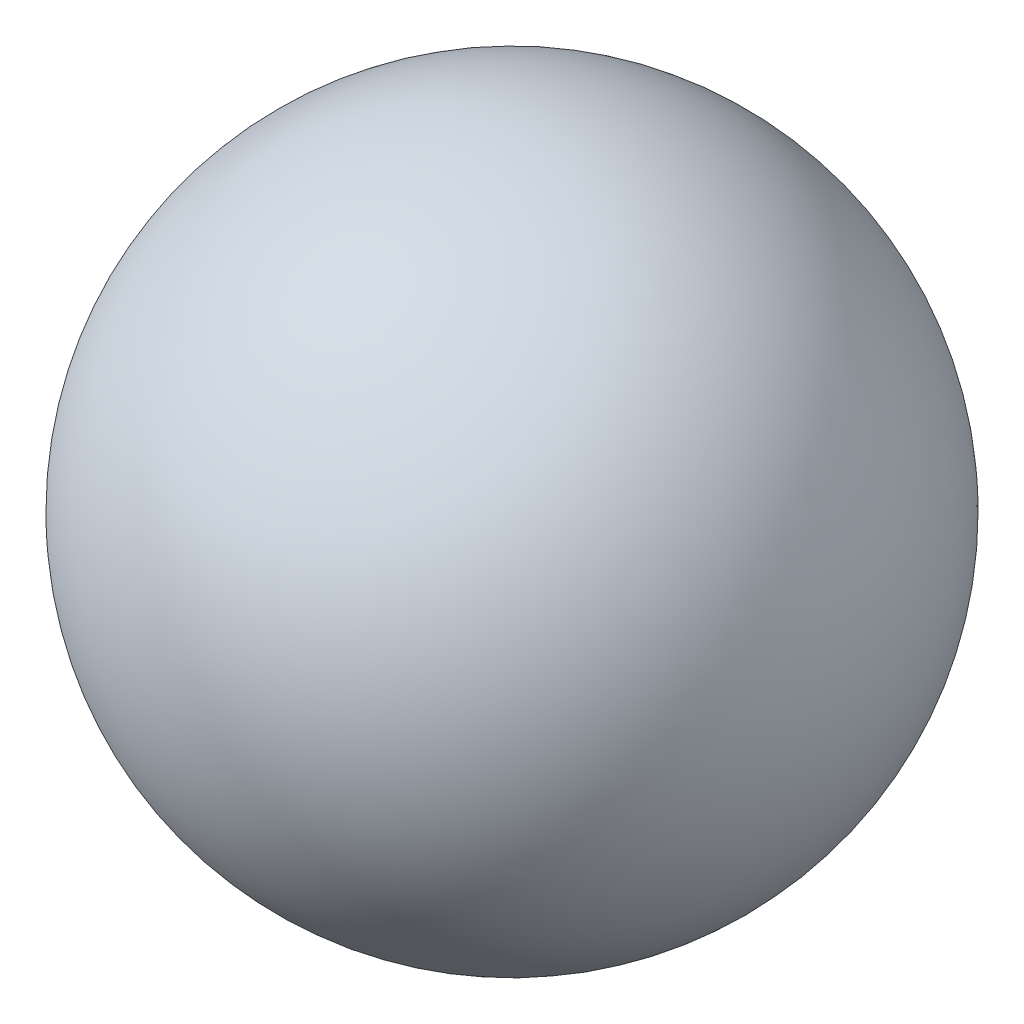
from build123d import *


with BuildPart() as part:
    # Sketch2 → Revolve1 (revolve)
    with BuildSketch(Plane(origin=(0, 0, 0), x_dir=(1, 0, 0), z_dir=(0, 1, 0))):
        with BuildLine():
            Line((0, 0), (10.315244795, 12.230933114))
            ThreePointArc((10.315244795, 12.230933114), (-0.957844159, 11.273088954), (0, 0))
        make_face()
    revolve(axis=Axis((0, 0, 0), (0.6447028, 0, -0.76443332)))


solid = part.part
